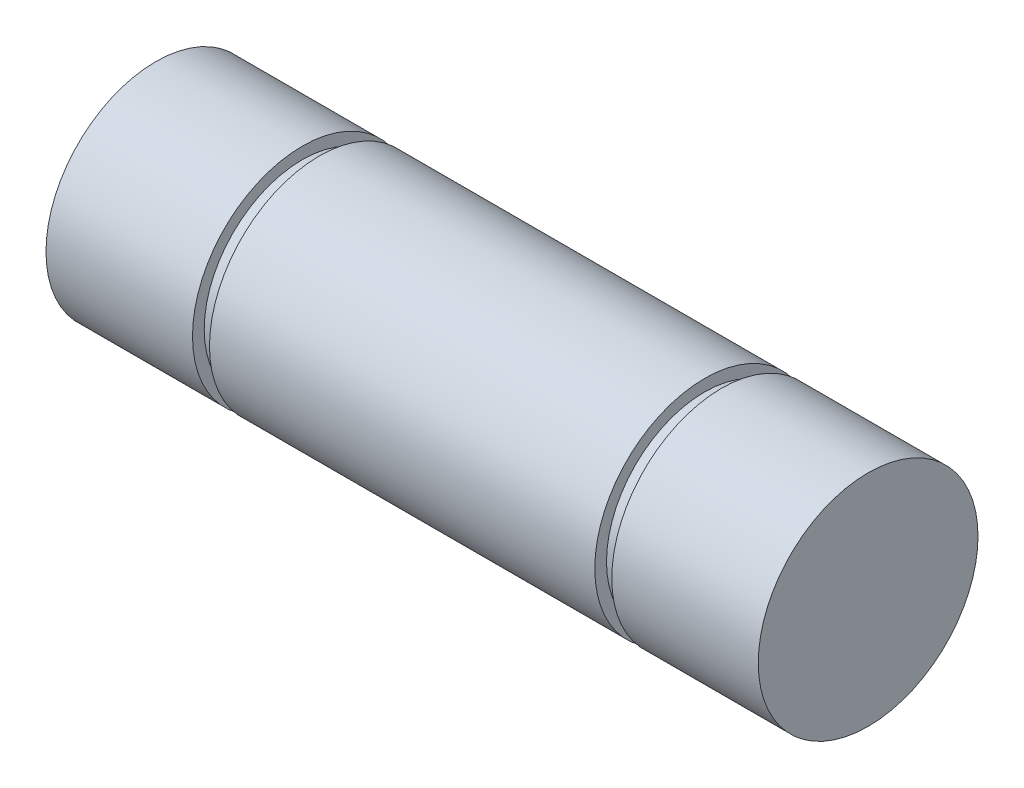
from build123d import *


with BuildPart() as part:
    # Sketch2 → Revolve1 (revolve)
    with BuildSketch(Plane.XY):
        Polygon((439.54135273, 274.410000074), (439.54135273, 279.172500074), (445.89135273, 279.172500074), (445.89135273, 278.664500074), (446.62795273, 278.664500074), (446.62795273, 279.172500074), (463.32975273, 279.172500074), (463.32975273, 278.664500074), (464.06635273, 278.664500074), (464.06635273, 279.172500074), (470.41635273, 279.172500074), (470.41635273, 274.410000074), align=None)
    revolve(axis=Axis((439.54135273, 274.410000074, 0), (1, 0, 0)))


solid = part.part
